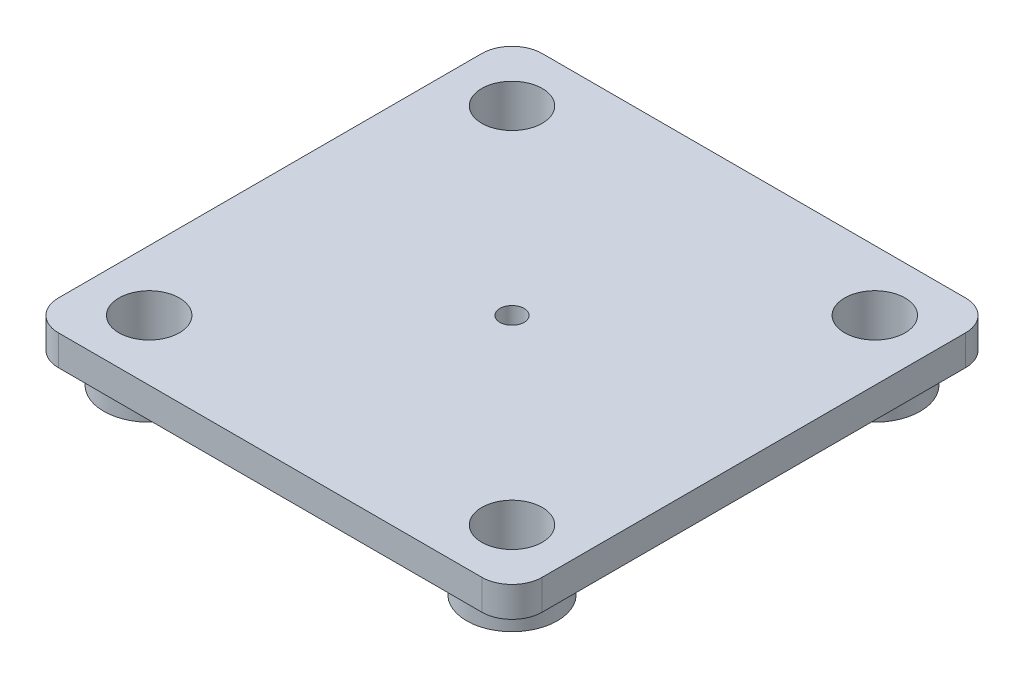
from build123d import *

# Parameters (mm, degrees)
SKETCH1_W           = 80
SKETCH1_H           = 80
SKETCH1_R           = 5
BOSS_EXTRUDE1_DEPTH = 5
SKETCH2_R           = 7.5
SKETCH2_R_2         = 5
EXTRUDE_THIN1_DEPTH = 5
SKETCH3_R           = 2
CUT_EXTRUDE1_DEPTH  = 11
FILLET1_R           = 5


with BuildPart() as part:
    # Sketch1 → Boss-Extrude1 (new body)
    with BuildSketch(Plane(origin=(0, 0, 0), x_dir=(1, 0, 0), z_dir=(0, 1, 0))):
        Rectangle(SKETCH1_W, SKETCH1_H)
        with Locations((-30, 30)):
            Circle(SKETCH1_R, mode=Mode.SUBTRACT)
        with Locations((30, 30)):
            Circle(SKETCH1_R, mode=Mode.SUBTRACT)
        with Locations((30, -30)):
            Circle(SKETCH1_R, mode=Mode.SUBTRACT)
        with Locations((-30, -30)):
            Circle(SKETCH1_R, mode=Mode.SUBTRACT)
    extrude(amount=BOSS_EXTRUDE1_DEPTH)

    # Sketch2 → Extrude-Thin1 (add)
    with BuildSketch(Plane.XZ):
        with Locations((-30, -30)):
            Circle(SKETCH2_R)
        with Locations((-30, -30)):
            Circle(SKETCH2_R_2, mode=Mode.SUBTRACT)
        with Locations((30, -30)):
            Circle(SKETCH2_R)
        with Locations((30, -30)):
            Circle(SKETCH2_R_2, mode=Mode.SUBTRACT)
        with Locations((30, 30)):
            Circle(SKETCH2_R)
        with Locations((30, 30)):
            Circle(SKETCH2_R_2, mode=Mode.SUBTRACT)
        with Locations((-30, 30)):
            Circle(SKETCH2_R)
        with Locations((-30, 30)):
            Circle(SKETCH2_R_2, mode=Mode.SUBTRACT)
    extrude(amount=EXTRUDE_THIN1_DEPTH)

    # Sketch3 → Cut-Extrude1 (cut, through all)
    with BuildSketch(Plane(origin=(0, 5, 0), x_dir=(1, 0, 0), z_dir=(0, 1, 0))):
        Circle(SKETCH3_R)
    extrude(amount=-CUT_EXTRUDE1_DEPTH, mode=Mode.SUBTRACT)

    # Fillet1
    fillet1_edges = [part.edges().sort_by_distance(p)[0] for p in [
        (40, 2.5, 40),
        (-40, 2.5, 40),
        (-40, 2.5, -40),
        (40, 2.5, -40),
    ]]
    fillet(fillet1_edges, radius=FILLET1_R)


solid = part.part
